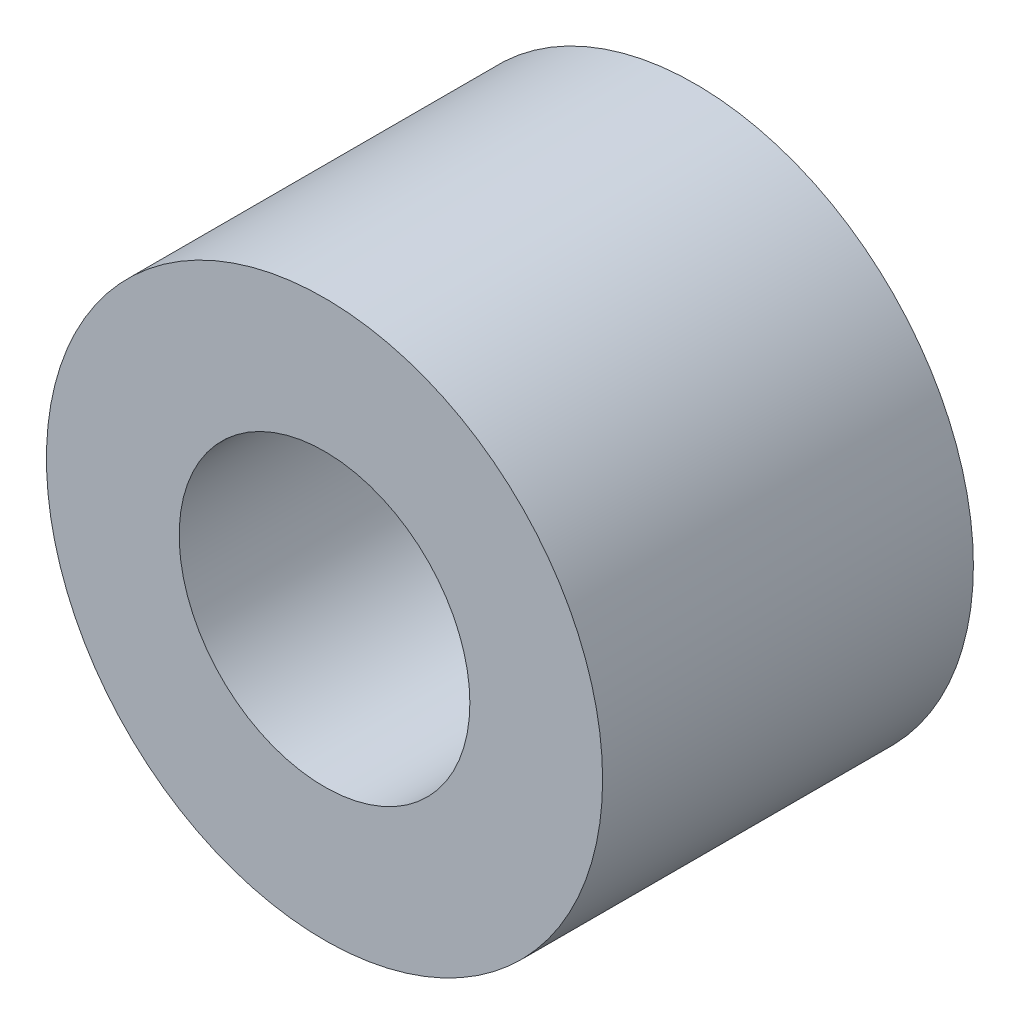
from build123d import *

# Parameters (mm, degrees)
SKETCH1_R           = 4.7625
SKETCH1_R_2         = 2.4892
BOSS_EXTRUDE1_DEPTH = 3.175


with BuildPart() as part:
    # Sketch1 → Boss-Extrude1 (new body, symmetric)
    with BuildSketch(Plane.XY):
        Circle(SKETCH1_R)
        Circle(SKETCH1_R_2, mode=Mode.SUBTRACT)
    extrude(amount=BOSS_EXTRUDE1_DEPTH, both=True)


solid = part.part
